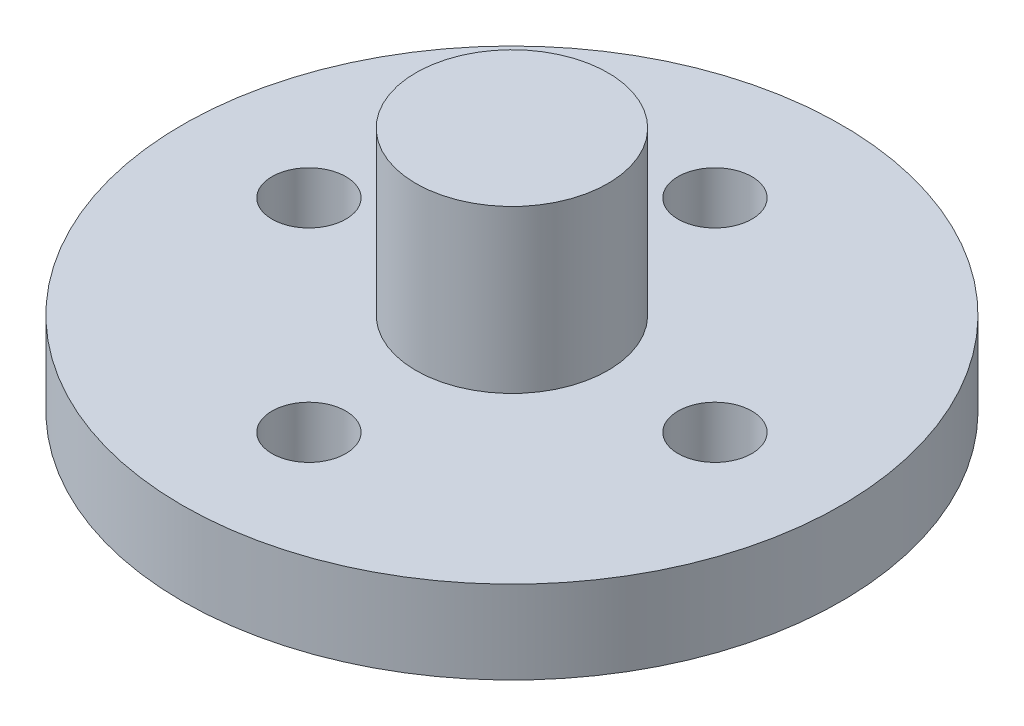
from build123d import *

# Parameters (mm, degrees)
SKETCH1_R           = 0.5
SKETCH1_R_2         = 1.375
BOSS_EXTRUDE1_DEPTH = 2
SKETCH4_R           = 4.6270037
SKETCH4_R_2         = 2.6270037
BOSS_EXTRUDE3_DEPTH = 6.5
CUT_EXTRUDE3_DEPTH  = 6.5
SKETCH6_R           = 15.875
SKETCH6_R_2         = 3.75
BOSS_EXTRUDE6_DEPTH = 2.54
SKETCH7_R           = 1.778
CUT_EXTRUDE4_DEPTH  = 2.54
CIRPATTERN1_COUNT   = 4
ESQUISSE1_R         = 15.875
ESQUISSE1_R_2       = 1.375
ESQUISSE1_R_3       = 1.778
BOSS_EXTRU_1_DEPTH  = 1.46
ESQUISSE2_R         = 4.625
BOSS_EXTRU_2_DEPTH  = 7.8


with BuildPart() as part:
    # Sketch1 → Boss-Extrude1 (new body)
    with BuildSketch(Plane(origin=(0, 0, 0), x_dir=(1, 0, 0), z_dir=(0, 1, 0))):
        with BuildLine():
            Line((-4, 4), (-2.467435953, 13.402193757))
            ThreePointArc((-2.467435953, 13.402193757), (0, 15.5), (2.467435953, 13.402193757))
            Line((2.467435953, 13.402193757), (4, 4))
            Line((4, 4), (12.448472752, 2.459445505))
            ThreePointArc((12.448472752, 2.459445505), (14.5, 0), (12.448472752, -2.459445505))
            Line((12.448472752, -2.459445505), (4, -4))
            Line((4, -4), (2.467435953, -13.402193757))
            ThreePointArc((2.467435953, -13.402193757), (0, -15.5), (-2.467435953, -13.402193757))
            Line((-2.467435953, -13.402193757), (-4, -4))
            Line((-4, -4), (-12.448472752, -2.459445505))
            ThreePointArc((-12.448472752, -2.459445505), (-14.5, 0), (-12.448472752, 2.459445505))
            Line((-12.448472752, 2.459445505), (-4, 4))
        make_face()
        with Locations((0, 12)):
            Circle(SKETCH1_R, mode=Mode.SUBTRACT)
        with Locations((0, 9.5)):
            Circle(SKETCH1_R, mode=Mode.SUBTRACT)
        with Locations((0, 7.5)):
            Circle(SKETCH1_R, mode=Mode.SUBTRACT)
        with Locations((12, 0)):
            Circle(SKETCH1_R, mode=Mode.SUBTRACT)
        with Locations((9.5, 0)):
            Circle(SKETCH1_R, mode=Mode.SUBTRACT)
        with Locations((7.5, 0)):
            Circle(SKETCH1_R, mode=Mode.SUBTRACT)
        with Locations((0, -12)):
            Circle(SKETCH1_R, mode=Mode.SUBTRACT)
        with Locations((0, -9.5)):
            Circle(SKETCH1_R, mode=Mode.SUBTRACT)
        with Locations((0, -7.5)):
            Circle(SKETCH1_R, mode=Mode.SUBTRACT)
        with Locations((-12, 0)):
            Circle(SKETCH1_R, mode=Mode.SUBTRACT)
        with Locations((-9.5, 0)):
            Circle(SKETCH1_R, mode=Mode.SUBTRACT)
        with Locations((-7.5, 0)):
            Circle(SKETCH1_R, mode=Mode.SUBTRACT)
        Circle(SKETCH1_R_2, mode=Mode.SUBTRACT)
    extrude(amount=BOSS_EXTRUDE1_DEPTH)

    # Sketch4 → Boss-Extrude3 (add)
    with BuildSketch(Plane.XZ):
        Circle(SKETCH4_R)
        Circle(SKETCH4_R_2, mode=Mode.SUBTRACT)
    extrude(amount=BOSS_EXTRUDE3_DEPTH)

    # Sketch5 → Cut-Extrude3 (cut)
    with BuildSketch(Plane.XZ.offset(6.5)):
        with BuildLine():
            Line((0.282820055, 2.611735296), (0, 3.101594))
            Line((0, 3.101594), (-0.282820055, 2.611735296))
            ThreePointArc((-0.282820055, 2.611735296), (0, 2.6270037), (0.282820055, 2.611735296))
        make_face()
        with BuildLine():
            ThreePointArc((-1.076048447, 2.396511669), (-0.811788788, 2.498428987), (-0.538092735, 2.571304075))
            Line((-0.538092735, 2.571304075), (-0.958445256, 2.949791185))
            Line((-0.958445256, 2.949791185), (-1.076048447, 2.396511669))
        make_face()
        with BuildLine():
            Line((0.958445256, 2.949791185), (0.538092735, 2.571304075))
            ThreePointArc((0.538092735, 2.571304075), (0.811788788, 2.498428987), (1.076048447, 2.396511669))
            Line((1.076048447, 2.396511669), (0.958445256, 2.949791185))
        make_face()
        with BuildLine():
            ThreePointArc((-1.76394572, 1.946700782), (-1.544114033, 2.125290638), (-1.306333259, 2.279175696))
            Line((-1.306333259, 2.279175696), (-1.823071212, 2.509242256))
            Line((-1.823071212, 2.509242256), (-1.76394572, 1.946700782))
        make_face()
        with BuildLine():
            Line((1.823071212, 2.509242256), (1.306333259, 2.279175696))
            ThreePointArc((1.306333259, 2.279175696), (1.544114033, 2.125290638), (1.76394572, 1.946700782))
            Line((1.76394572, 1.946700782), (1.823071212, 2.509242256))
        make_face()
        with BuildLine():
            ThreePointArc((-2.279175696, 1.306333259), (-2.125290638, 1.544114033), (-1.946700782, 1.76394572))
            Line((-1.946700782, 1.76394572), (-2.509242256, 1.823071212))
            Line((-2.509242256, 1.823071212), (-2.279175696, 1.306333259))
        make_face()
        with BuildLine():
            Line((2.509242256, 1.823071212), (1.946700782, 1.76394572))
            ThreePointArc((1.946700782, 1.76394572), (2.125290638, 1.544114033), (2.279175696, 1.306333259))
            Line((2.279175696, 1.306333259), (2.509242256, 1.823071212))
        make_face()
        with BuildLine():
            ThreePointArc((-2.571304075, 0.538092735), (-2.498428987, 0.811788788), (-2.396511669, 1.076048447))
            Line((-2.396511669, 1.076048447), (-2.949791185, 0.958445256))
            Line((-2.949791185, 0.958445256), (-2.571304075, 0.538092735))
        make_face()
        with BuildLine():
            Line((2.949791185, 0.958445256), (2.396511669, 1.076048447))
            ThreePointArc((2.396511669, 1.076048447), (2.498428987, 0.811788788), (2.571304075, 0.538092735))
            Line((2.571304075, 0.538092735), (2.949791185, 0.958445256))
        make_face()
        with BuildLine():
            ThreePointArc((-2.611735296, -0.282820055), (-2.6270037, 0), (-2.611735296, 0.282820055))
            Line((-2.611735296, 0.282820055), (-3.101594, 0))
            Line((-3.101594, 0), (-2.611735296, -0.282820055))
        make_face()
        with BuildLine():
            Line((3.101594, 0), (2.611735296, 0.282820055))
            ThreePointArc((2.611735296, 0.282820055), (2.6270037, 0), (2.611735296, -0.282820055))
            Line((2.611735296, -0.282820055), (3.101594, 0))
        make_face()
        with BuildLine():
            ThreePointArc((-2.396511669, -1.076048447), (-2.498428987, -0.811788788), (-2.571304075, -0.538092735))
            Line((-2.571304075, -0.538092735), (-2.949791185, -0.958445256))
            Line((-2.949791185, -0.958445256), (-2.396511669, -1.076048447))
        make_face()
        with BuildLine():
            Line((2.949791185, -0.958445256), (2.571304075, -0.538092735))
            ThreePointArc((2.571304075, -0.538092735), (2.498428987, -0.811788788), (2.396511669, -1.076048447))
            Line((2.396511669, -1.076048447), (2.949791185, -0.958445256))
        make_face()
        with BuildLine():
            ThreePointArc((-1.946700782, -1.76394572), (-2.125290638, -1.544114033), (-2.279175696, -1.306333259))
            Line((-2.279175696, -1.306333259), (-2.509242256, -1.823071212))
            Line((-2.509242256, -1.823071212), (-1.946700782, -1.76394572))
        make_face()
        with BuildLine():
            Line((2.509242256, -1.823071212), (2.279175696, -1.306333259))
            ThreePointArc((2.279175696, -1.306333259), (2.125290638, -1.544114033), (1.946700782, -1.76394572))
            Line((1.946700782, -1.76394572), (2.509242256, -1.823071212))
        make_face()
        with BuildLine():
            ThreePointArc((-1.306333259, -2.279175696), (-1.544114033, -2.125290638), (-1.76394572, -1.946700782))
            Line((-1.76394572, -1.946700782), (-1.823071212, -2.509242256))
            Line((-1.823071212, -2.509242256), (-1.306333259, -2.279175696))
        make_face()
        with BuildLine():
            Line((1.823071212, -2.509242256), (1.76394572, -1.946700782))
            ThreePointArc((1.76394572, -1.946700782), (1.544114033, -2.125290638), (1.306333259, -2.279175696))
            Line((1.306333259, -2.279175696), (1.823071212, -2.509242256))
        make_face()
        with BuildLine():
            ThreePointArc((-0.538092735, -2.571304075), (-0.811788788, -2.498428987), (-1.076048447, -2.396511669))
            Line((-1.076048447, -2.396511669), (-0.958445256, -2.949791185))
            Line((-0.958445256, -2.949791185), (-0.538092735, -2.571304075))
        make_face()
        with BuildLine():
            Line((0.958445256, -2.949791185), (1.076048447, -2.396511669))
            ThreePointArc((1.076048447, -2.396511669), (0.811788788, -2.498428987), (0.538092735, -2.571304075))
            Line((0.538092735, -2.571304075), (0.958445256, -2.949791185))
        make_face()
        with BuildLine():
            ThreePointArc((0.282820055, -2.611735296), (0, -2.6270037), (-0.282820055, -2.611735296))
            Line((-0.282820055, -2.611735296), (0, -3.101594))
            Line((0, -3.101594), (0.282820055, -2.611735296))
        make_face()
    extrude(amount=-CUT_EXTRUDE3_DEPTH, mode=Mode.SUBTRACT)

    # Sketch6 → Boss-Extrude6 (add)
    with BuildSketch(Plane(origin=(0, 2, 0), x_dir=(1, 0, 0), z_dir=(0, 1, 0))):
        Circle(SKETCH6_R)
        Circle(SKETCH6_R_2, mode=Mode.SUBTRACT)
    extrude(amount=-BOSS_EXTRUDE6_DEPTH)

    # Sketch7 → Cut-Extrude4 (cut)
    with BuildSketch(Plane(origin=(0, 2, 0), x_dir=(1, 0, 0), z_dir=(0, 1, 0))):
        with Locations((0, 9.779)):
            Circle(SKETCH7_R)
    cut_extrude4 = extrude(amount=-CUT_EXTRUDE4_DEPTH, mode=Mode.SUBTRACT)

    # CirPattern1: Cut-Extrude4 ×4 about axis
    cirpattern1_axis = Axis((0, 0, 0), (0, 1, 0))
    for i in range(1, CIRPATTERN1_COUNT):
        add(cut_extrude4.rotate(cirpattern1_axis, i * 360 / CIRPATTERN1_COUNT), mode=Mode.SUBTRACT)

    # Esquisse1 → Boss.-Extru.1 (add)
    with BuildSketch(Plane(origin=(0, 2, 0), x_dir=(1, 0, 0), z_dir=(0, 1, 0))):
        Circle(ESQUISSE1_R)
        Circle(ESQUISSE1_R_2, mode=Mode.SUBTRACT)
        with Locations((0, 9.779)):
            Circle(ESQUISSE1_R_3, mode=Mode.SUBTRACT)
        with Locations((9.779, 0)):
            Circle(ESQUISSE1_R_3, mode=Mode.SUBTRACT)
        with Locations((0, -9.779)):
            Circle(ESQUISSE1_R_3, mode=Mode.SUBTRACT)
        with Locations((-9.779, 0)):
            Circle(ESQUISSE1_R_3, mode=Mode.SUBTRACT)
    extrude(amount=BOSS_EXTRU_1_DEPTH)

    # Esquisse2 → Boss.-Extru.2 (add)
    with BuildSketch(Plane(origin=(0, 3.46, 0), x_dir=(1, 0, 0), z_dir=(0, 1, 0))):
        Circle(ESQUISSE2_R)
    extrude(amount=BOSS_EXTRU_2_DEPTH)


solid = part.part
